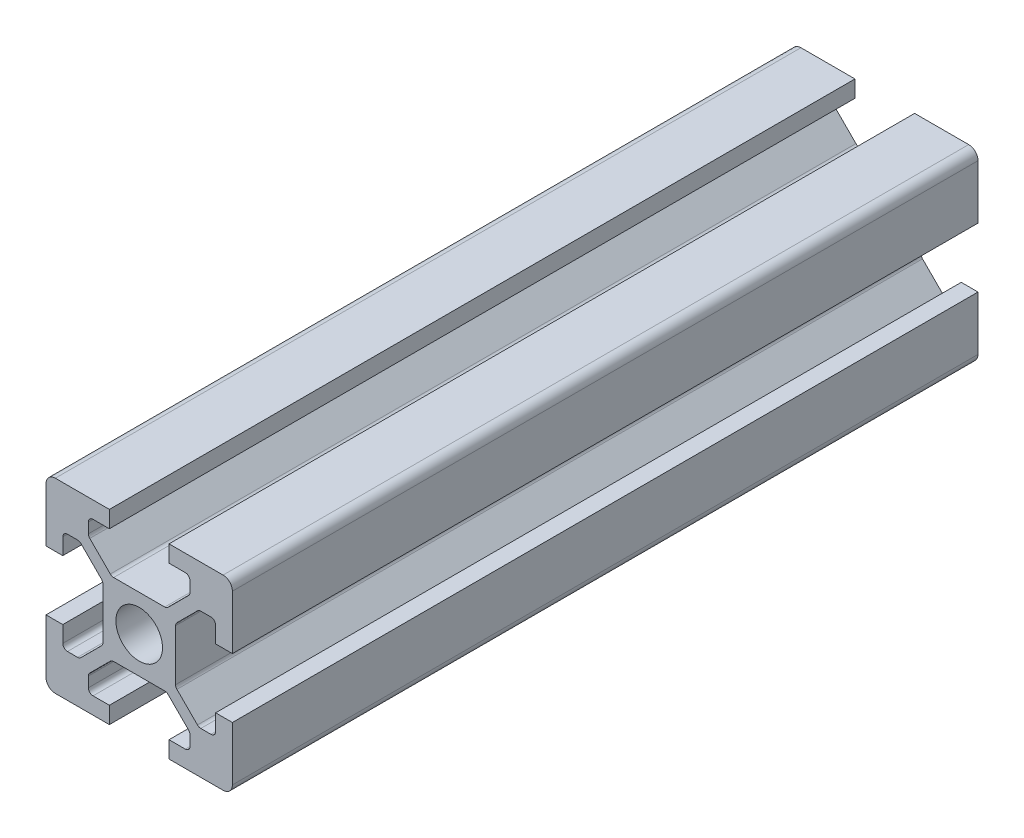
from build123d import *

# Parameters (mm, degrees)
SKETCH1_R           = 2.5
BOSS_EXTRUDE1_DEPTH = 80
FILLET1_R           = 1
FILLET2_R           = 0.5
FILLET3_R           = 0.5
FILLET4_R           = 0.5
FILLET5_R           = 0.5
SKETCH2_R           = 2.5
CUT_EXTRUDE1_DEPTH  = 8


with BuildPart() as part:
    # Sketch1 → Boss-Extrude1 (new body)
    with BuildSketch(Plane.XY):
        Polygon((13.2, 0), (13.2, 1.8), (15.45, 1.8), (15.45, 3.6), (12.95, 6.1), (7.05, 6.1), (4.55, 3.6), (4.55, 1.8), (6.8, 1.8), (6.8, 0), (0, 0), (0, 6.8), (1.8, 6.8), (1.8, 4.55), (3.6, 4.55), (6.1, 7.05), (6.1, 12.95), (3.6, 15.45), (1.8, 15.45), (1.8, 13.2), (0, 13.2), (0, 20), (6.8, 20), (6.8, 18.2), (4.55, 18.2), (4.55, 16.4), (7.05, 13.9), (12.95, 13.9), (15.45, 16.4), (15.45, 18.2), (13.2, 18.2), (13.2, 20), (20, 20), (20, 13.2), (18.2, 13.2), (18.2, 15.45), (16.4, 15.45), (13.9, 12.95), (13.9, 7.05), (16.4, 4.55), (18.2, 4.55), (18.2, 6.8), (20, 6.8), (20, 0), align=None)
        with Locations((10, 10)):
            Circle(SKETCH1_R, mode=Mode.SUBTRACT)
    extrude(amount=BOSS_EXTRUDE1_DEPTH)

    # Fillet1
    fillet1_edges = [part.edges().sort_by_distance(p)[0] for p in [
        (0, 0, 40),
        (0, 20, 40),
        (20, 20, 40),
        (20, 0, 40),
    ]]
    fillet(fillet1_edges, radius=FILLET1_R)

    # Fillet2
    fillet2_edges = [part.edges().sort_by_distance(p)[0] for p in [
        (4.55, 18.2, 40),
        (4.55, 16.4, 40),
        (7.05, 13.9, 40),
        (12.95, 13.9, 40),
        (15.45, 16.4, 40),
        (15.45, 18.2, 40),
    ]]
    fillet(fillet2_edges, radius=FILLET2_R)

    # Fillet3
    fillet3_edges = [part.edges().sort_by_distance(p)[0] for p in [
        (18.2, 15.45, 40),
        (16.4, 15.45, 40),
        (13.9, 12.95, 40),
        (13.9, 7.05, 40),
        (16.4, 4.55, 40),
        (18.2, 4.55, 40),
    ]]
    fillet(fillet3_edges, radius=FILLET3_R)

    # Fillet4
    fillet4_edges = [part.edges().sort_by_distance(p)[0] for p in [
        (1.8, 4.55, 40),
        (3.6, 4.55, 40),
        (6.1, 7.05, 40),
        (6.1, 12.95, 40),
        (3.6, 15.45, 40),
        (1.8, 15.45, 40),
    ]]
    fillet(fillet4_edges, radius=FILLET4_R)

    # Fillet5
    fillet5_edges = [part.edges().sort_by_distance(p)[0] for p in [
        (15.45, 1.8, 40),
        (15.45, 3.6, 40),
        (12.95, 6.1, 40),
        (7.05, 6.1, 40),
        (4.55, 3.6, 40),
        (4.55, 1.8, 40),
    ]]
    fillet(fillet5_edges, radius=FILLET5_R)

    # Sketch2 → Cut-Extrude1 (cut)
    with BuildSketch(Plane(origin=(0, 13.9, 0), x_dir=(1, 0, 0), z_dir=(0, 1, 0))):
        with Locations((10, -58)):
            Circle(SKETCH2_R)
        with Locations((10, -70)):
            Circle(SKETCH2_R)
        with Locations((10, -34)):
            Circle(SKETCH2_R)
        with Locations((10, -46)):
            Circle(SKETCH2_R)
        with Locations((10, -22)):
            Circle(SKETCH2_R)
        with Locations((10, -10)):
            Circle(SKETCH2_R)
    extrude(amount=-CUT_EXTRUDE1_DEPTH, mode=Mode.SUBTRACT)


solid = part.part
